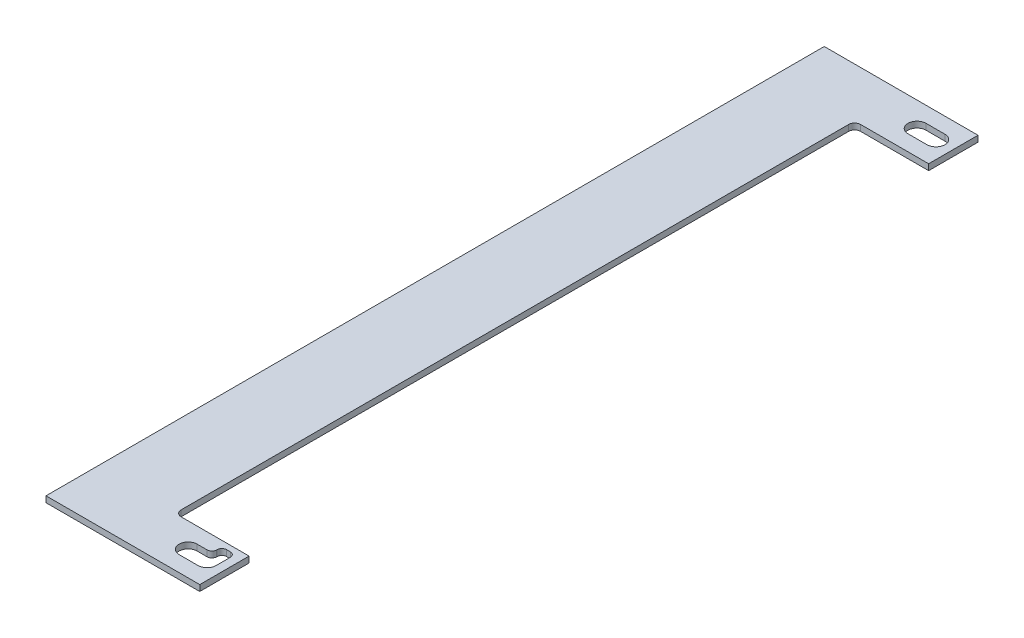
from build123d import *

# Parameters (mm, degrees)
EXTRUDE1_DEPTH     = 3.175
CUT_EXTRUDE2_DEPTH = 4.175
FILLET1_R          = 2.5
FILLET2_R          = 3.175


with BuildPart() as part:
    # Sketch1 → Extrude1 (new body)
    with BuildSketch(Plane(origin=(0, 0, 0), x_dir=(1, 0, 0), z_dir=(0, 1, 0))):
        Polygon((-69.865, 256.29975), (11.135, 256.29975), (11.135, 248.06225), (11.135, 238.53725), (11.135, 230.29975), (-27.865, 230.29975), (-27.865, -127.70025), (11.135, -127.70025), (11.135, -145.46275), (11.135, -153.70025), (-69.865, -153.70025), align=None)
        with BuildLine():
            Line((-8, -135.93775), (2, -135.93775))
            ThreePointArc((2, -135.93775), (6.7625, -140.70025), (2, -145.46275))
            Line((2, -145.46275), (-8, -145.46275))
            ThreePointArc((-8, -145.46275), (-12.7625, -140.70025), (-8, -135.93775))
        make_face(mode=Mode.SUBTRACT)
        with BuildLine():
            Line((-8, 248.06225), (2, 248.06225))
            ThreePointArc((2, 248.06225), (6.7625, 243.29975), (2, 238.53725))
            Line((2, 238.53725), (-8, 238.53725))
            ThreePointArc((-8, 238.53725), (-12.7625, 243.29975), (-8, 248.06225))
        make_face(mode=Mode.SUBTRACT)
    extrude(amount=EXTRUDE1_DEPTH)

    # Sketch2 → Cut-Extrude2 (cut, through all)
    with BuildSketch(Plane(origin=(0, 3.175, 0), x_dir=(1, 0, 0), z_dir=(0, 1, 0))):
        with BuildLine():
            Line((-0.2375, -135.93775), (-0.2375, -130.70025))
            Line((-0.2375, -130.70025), (6.7625, -130.70025))
            Line((6.7625, -130.70025), (6.7625, -140.70025))
            ThreePointArc((6.7625, -140.70025), (5.367596045, -137.332653955), (2, -135.93775))
            Line((2, -135.93775), (-0.2375, -135.93775))
        make_face()
    extrude(amount=-CUT_EXTRUDE2_DEPTH, mode=Mode.SUBTRACT)

    # Fillet1
    fillet1_edges = [part.edges().sort_by_distance(p)[0] for p in [
        (-0.2375, 1.5875, 135.93775),
        (-0.2375, 1.5875, 130.70025),
        (6.7625, 1.5875, 130.70025),
    ]]
    fillet(fillet1_edges, radius=FILLET1_R)

    # Fillet2
    fillet2_edges = [part.edges().sort_by_distance(p)[0] for p in [
        (-27.865, 1.5875, -230.29975),
        (-27.865, 1.5875, 127.70025),
    ]]
    fillet(fillet2_edges, radius=FILLET2_R)


solid = part.part
